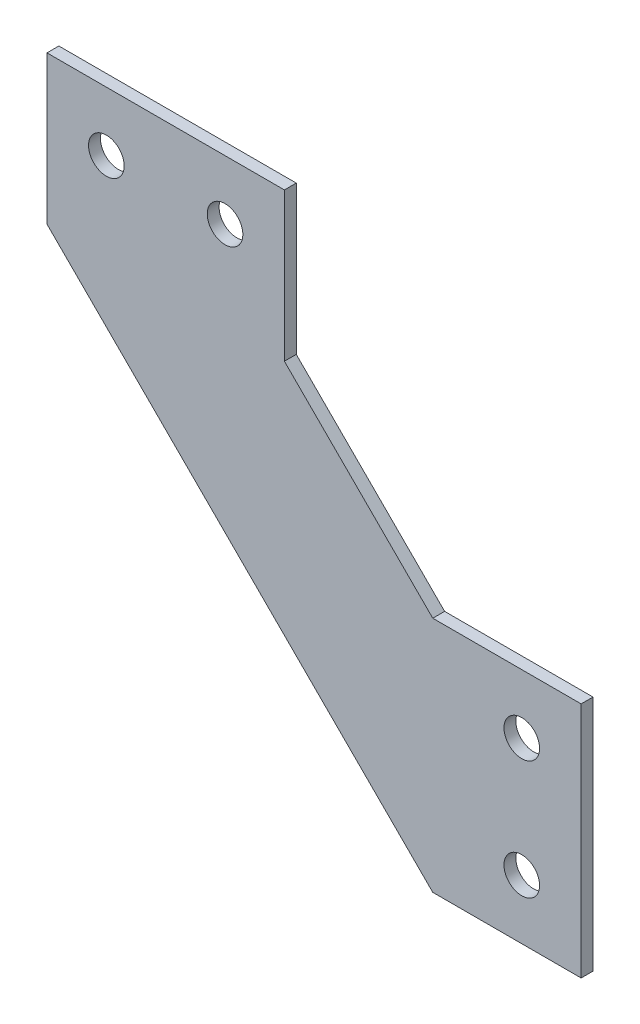
from build123d import *

# Parameters (mm, degrees)
SKETCH1_R           = 3
BOSS_EXTRUDE1_DEPTH = 2


with BuildPart() as part:
    # Sketch1 → Boss-Extrude1 (new body)
    with BuildSketch(Plane(origin=(0, 0, 59.299394977), x_dir=(-1, 0, 0), z_dir=(0, 0, -1))):
        Polygon((212.035137501, 44.5501261), (212.035137501, 39.5501261), (147.035137501, -25.4498739), (142.035137501, -25.4498739), (122.035137501, -25.4498739), (122.035137501, 14.5501261), (142.035137501, 14.5501261), (147.035137501, 14.5501261), (172.035137501, 39.5501261), (172.035137501, 44.5501261), (172.035137501, 64.5501261), (212.035137501, 64.5501261), align=None)
        with Locations((202.035137501, 54.5501261)):
            Circle(SKETCH1_R, mode=Mode.SUBTRACT)
        with Locations((182.035137501, 54.5501261)):
            Circle(SKETCH1_R, mode=Mode.SUBTRACT)
        with Locations((132.035137501, -15.4498739)):
            Circle(SKETCH1_R, mode=Mode.SUBTRACT)
        with Locations((132.035137501, 4.5501261)):
            Circle(SKETCH1_R, mode=Mode.SUBTRACT)
    extrude(amount=BOSS_EXTRUDE1_DEPTH)


solid = part.part
